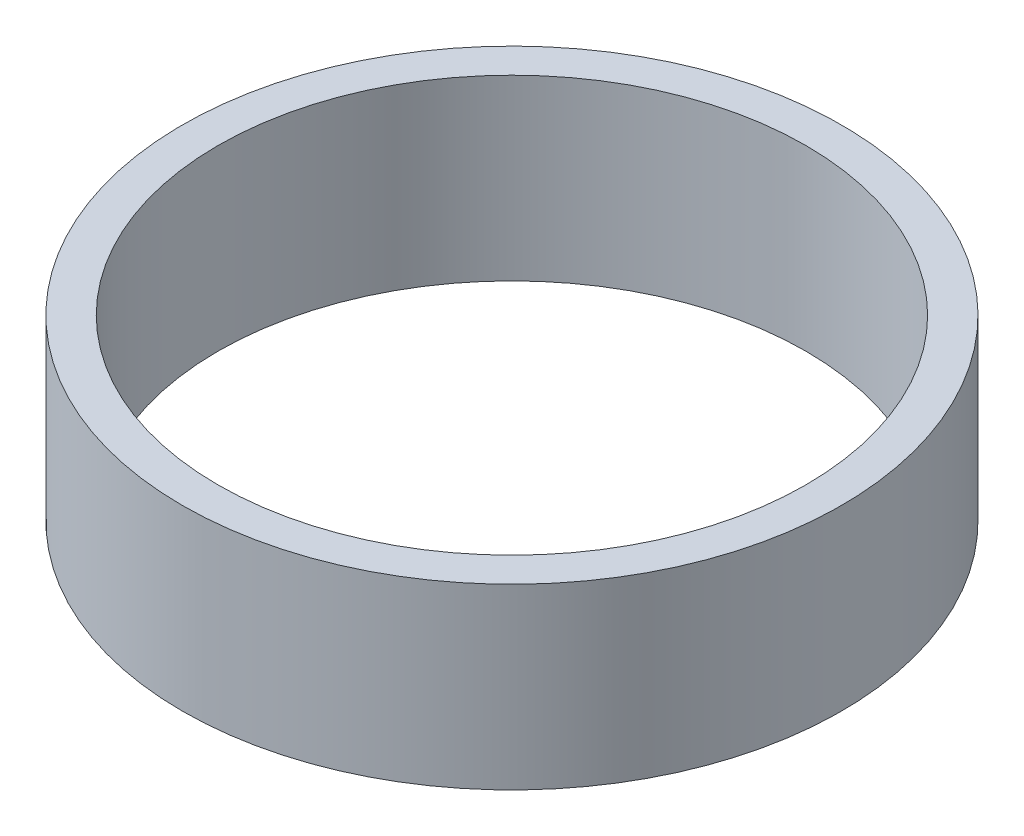
from build123d import *

# Parameters (mm, degrees)
SKETCH1_R           = 18.5
SKETCH1_R_2         = 16.5
BOSS_EXTRUDE1_DEPTH = 10


with BuildPart() as part:
    # Sketch1 → Boss-Extrude1 (new body)
    with BuildSketch(Plane(origin=(0, 0, 0), x_dir=(1, 0, 0), z_dir=(0, 1, 0))):
        Circle(SKETCH1_R)
        Circle(SKETCH1_R_2, mode=Mode.SUBTRACT)
    extrude(amount=BOSS_EXTRUDE1_DEPTH)


solid = part.part
